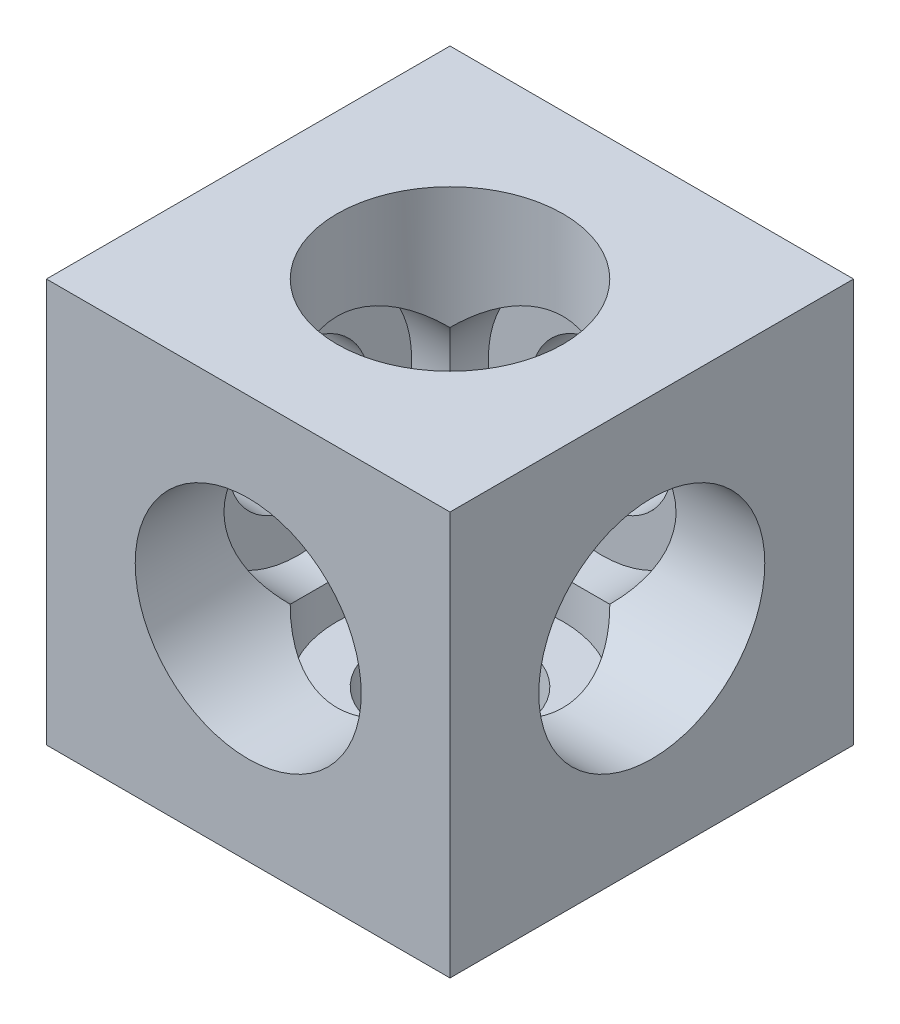
from build123d import *

# Parameters (mm, degrees)
SKETCH1_W           = 20
SKETCH1_H           = 20
BOSS_EXTRUDE1_DEPTH = 10
SKETCH2_R           = 3.5
CUT_EXTRUDE1_DEPTH  = 21
SKETCH3_R           = 3.5
CUT_EXTRUDE2_DEPTH  = 21
SKETCH4_R           = 3.5
CUT_EXTRUDE3_DEPTH  = 21
SKETCH5_R           = 5.6
CUT_EXTRUDE4_DEPTH  = 17.5
SKETCH6_R           = 5.6
CUT_EXTRUDE5_DEPTH  = 17.5
SKETCH7_R           = 5.6
CUT_EXTRUDE6_DEPTH  = 17.5


with BuildPart() as part:
    # Sketch1 → Boss-Extrude1 (new body, symmetric)
    with BuildSketch(Plane.XY):
        Rectangle(SKETCH1_W, SKETCH1_H)
    extrude(amount=BOSS_EXTRUDE1_DEPTH, both=True)

    # Sketch2 → Cut-Extrude1 (cut, through all)
    with BuildSketch(Plane(origin=(0, 10, 0), x_dir=(1, 0, 0), z_dir=(0, 1, 0))):
        Circle(SKETCH2_R)
    extrude(amount=-CUT_EXTRUDE1_DEPTH, mode=Mode.SUBTRACT)

    # Sketch3 → Cut-Extrude2 (cut, through all)
    with BuildSketch(Plane.XY.offset(10)):
        Circle(SKETCH3_R)
    extrude(amount=-CUT_EXTRUDE2_DEPTH, mode=Mode.SUBTRACT)

    # Sketch4 → Cut-Extrude3 (cut, through all)
    with BuildSketch(Plane(origin=(10, 0, 0), x_dir=(0, 0, -1), z_dir=(1, 0, 0))):
        Circle(SKETCH4_R)
    extrude(amount=-CUT_EXTRUDE3_DEPTH, mode=Mode.SUBTRACT)

    # Sketch5 → Cut-Extrude4 (cut)
    with BuildSketch(Plane(origin=(0, 10, 0), x_dir=(1, 0, 0), z_dir=(0, 1, 0))):
        Circle(SKETCH5_R)
    extrude(amount=-CUT_EXTRUDE4_DEPTH, mode=Mode.SUBTRACT)

    # Sketch6 → Cut-Extrude5 (cut)
    with BuildSketch(Plane.XY.offset(10)):
        Circle(SKETCH6_R)
    extrude(amount=-CUT_EXTRUDE5_DEPTH, mode=Mode.SUBTRACT)

    # Sketch7 → Cut-Extrude6 (cut)
    with BuildSketch(Plane(origin=(10, 0, 0), x_dir=(0, 0, -1), z_dir=(1, 0, 0))):
        Circle(SKETCH7_R)
    extrude(amount=-CUT_EXTRUDE6_DEPTH, mode=Mode.SUBTRACT)


solid = part.part
